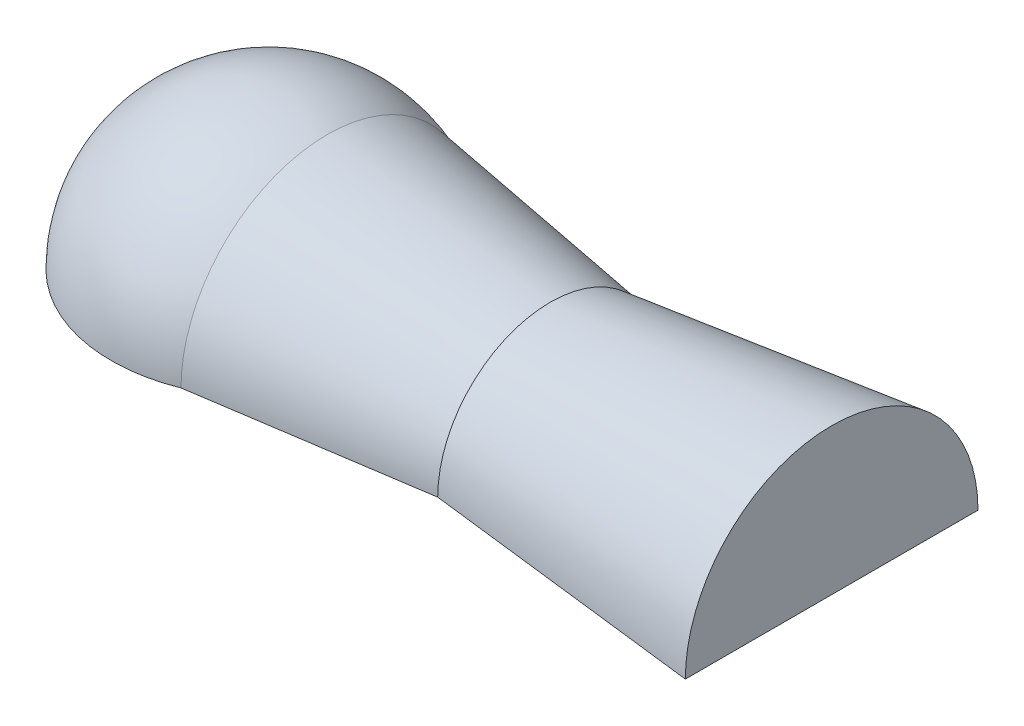
from build123d import *

# Parameters (mm, degrees)
REVOLVE_1_ANGLE = 180


with BuildPart() as part:
    # Эскиз1 → Повернуть1 (revolve)
    with BuildSketch(Plane(origin=(0, 0, 0), x_dir=(1, 0, 0), z_dir=(0, 1, 0))):
        with BuildLine():
            Line((0, 0), (250, 0))
            Line((250, 0), (250, 65))
            Line((250, 65), (125, 50))
            Line((125, 50), (25.980762114, 65))
            ThreePointArc((25.980762114, 65), (-39.251411771, 57.959698705), (-70, 0))
            Line((-70, 0), (0, 0))
        make_face()
    revolve(axis=Axis((0, 0, 0), (1, 0, 0)), revolution_arc=REVOLVE_1_ANGLE)


solid = part.part
